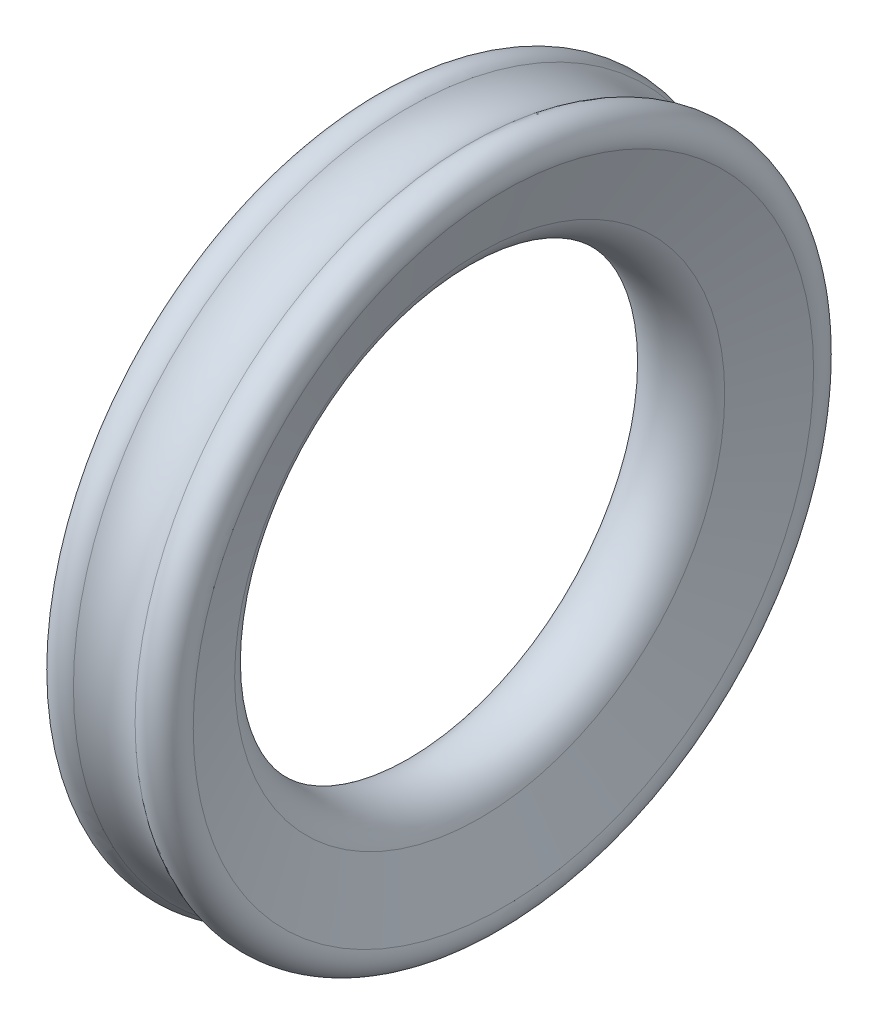
from build123d import *


with BuildPart() as part:
    # Sketch1 → Revolve1 (revolve)
    with BuildSketch(Plane.XY):
        with BuildLine():
            Line((5.638155725, 33.94787914), (8.923373054, 42.97393957))
            ThreePointArc((8.923373054, 42.97393957), (7.875677675, 46.421198897), (4.273006634, 46.376211737))
            ThreePointArc((4.273006634, 46.376211737), (0, 44.92070579), (-4.273006634, 46.376211737))
            ThreePointArc((-4.273006634, 46.376211737), (-7.875677675, 46.421198897), (-8.923373054, 42.97393957))
            Line((-8.923373054, 42.97393957), (-5.638155725, 33.94787914))
            ThreePointArc((-5.638155725, 33.94787914), (0, 30), (5.638155725, 33.94787914))
        make_face()
    revolve(axis=Axis((0, 0, 0), (1, 0, 0)))


solid = part.part
